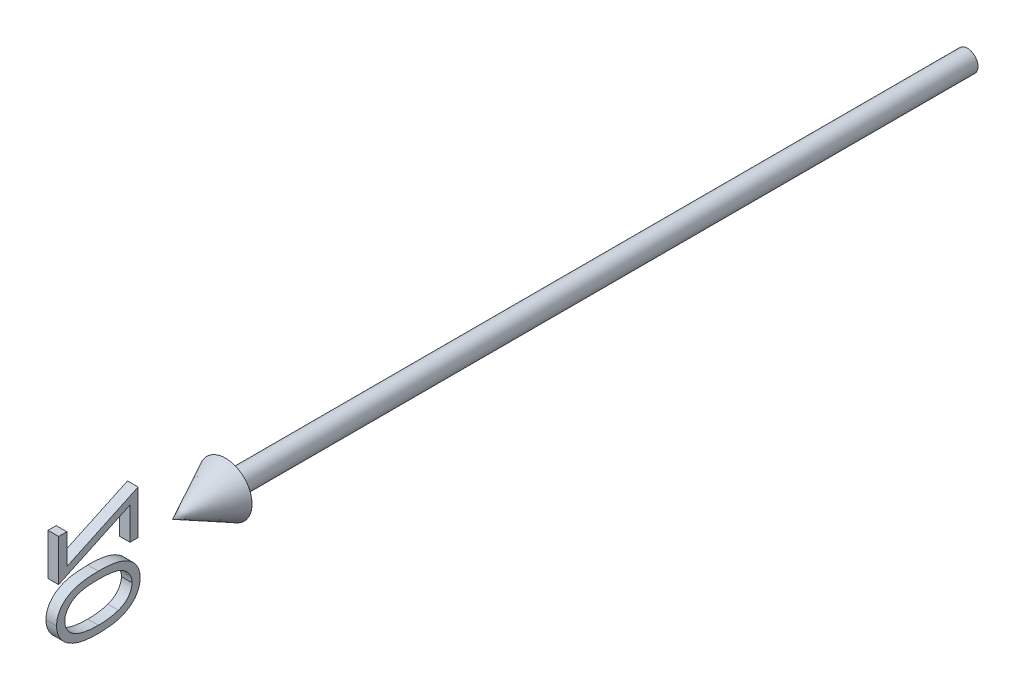
from build123d import *

# Parameters (mm, degrees)
BOSS_EXTRUDE1_DEPTH        = 1
BOSS_EXTRUDE1_DEPTH_BACK   = 1
BOSS_EXTRUDE1_2_DEPTH      = 1
BOSS_EXTRUDE1_2_DEPTH_BACK = 1


with BuildPart() as part:
    # Sketch2 → Revolve1 (revolve)
    with BuildSketch(Plane(origin=(0, 0, 0), x_dir=(1, 0, 0), z_dir=(0, 1, 0))):
        Polygon((0, -150), (5, -140), (2, -140), (2, 0), (0, 0), align=None)
    revolve(axis=Axis((0, 0, -41.949952025), (0, 0, 1)))


with BuildPart() as body_2:
    # Sketch3 → Boss-Extrude1 (new, two sides: drawn at the far end of the back side and taken through both)
    with BuildSketch(Plane(origin=(0, 0, 0), x_dir=(0, -1, 0), z_dir=(1, 0, 0)).offset(-BOSS_EXTRUDE1_DEPTH_BACK)):
        Polygon((-8.958586521, -170.961538462), (-8.958586521, -172.5), (-1.073971137, -172.5), (-7.366038444, -159.038461538), (-1.266278829, -159.038461538), (-1.266278829, -157.5), (-9.535509598, -157.5), (-3.243442291, -170.961538462), align=None)
    extrude(amount=BOSS_EXTRUDE1_DEPTH + BOSS_EXTRUDE1_DEPTH_BACK)


with BuildPart() as body_3:
    # Sketch3 → Boss-Extrude1 2 (new, two sides: drawn at the far end of the back side and taken through both)
    with BuildSketch(Plane(origin=(0, 0, 0), x_dir=(0, -1, 0), z_dir=(1, 0, 0)).offset(-BOSS_EXTRUDE1_2_DEPTH_BACK)):
        with BuildLine():
            add(Edge.make_bspline(
                [(0.464490402, -164.993990385), (0.465896194, -165.234407761), (0.468626965, -165.701421979), (0.499005913, -166.381927587), (0.549471662, -167.020328829), (0.618631845, -167.616656242), (0.702794571, -168.171063848), (0.815146812, -168.682069802), (0.942915443, -169.152040041), (1.090999113, -169.582504296), (1.258083581, -169.97927162), (1.439966057, -170.349645098), (1.643739441, -170.693182296), (1.858196956, -171.014944812), (2.090844214, -171.311694529), (2.340872181, -171.582097798), (2.606078592, -171.830344919), (2.88771833, -172.052353788), (3.183107018, -172.245804902), (3.483506669, -172.421163962), (3.7974853, -172.559877815), (4.117298457, -172.678494137), (4.445522801, -172.772454295), (4.782301317, -172.83781096), (5.127936212, -172.878699478), (5.361209824, -172.882624707), (5.47951444, -172.884615385)],
                knots=[0, 0, 0, 0, 1.64625301, 3.197870201, 4.6634513, 6.030635694, 7.308242971, 8.501545196, 9.611429483, 10.641742253, 11.616230371, 12.55791849, 13.464870342, 14.34944951, 15.20427819, 16.044004467, 16.869007726, 17.689551165, 18.496129964, 19.285613293, 20.0683943, 20.843080271, 21.620342827, 22.403213977, 23.190190624, 24, 24, 24, 24], degree=3))
            add(Edge.make_bspline(
                [(5.47951444, -172.884615385), (5.598867202, -172.882960028), (5.836337191, -172.879666451), (6.186159255, -172.83330737), (6.529888015, -172.773470363), (6.862308428, -172.677501658), (7.189705924, -172.562662656), (7.503938784, -172.411134418), (7.81610109, -172.246335691), (8.112011727, -172.045295108), (8.400511963, -171.823112179), (8.670950813, -171.570877754), (8.930241416, -171.295572446), (9.168590469, -170.991056145), (9.396213279, -170.661997985), (9.604469055, -170.305639513), (9.797689138, -169.922770469), (9.979505552, -169.515165777), (10.138499204, -169.071937683), (10.279857271, -168.595850718), (10.395724126, -168.082593685), (10.491543977, -167.535025751), (10.565918422, -166.950434272), (10.620046885, -166.330003698), (10.648649073, -165.673345879), (10.654034477, -165.224383527), (10.656798094, -164.993990385)],
                knots=[0, 0, 0, 0, 0.810910589, 1.61342667, 2.396193133, 3.181089899, 3.963115317, 4.752255436, 5.550715454, 6.36105385, 7.181178335, 8.024612154, 8.872680183, 9.750181803, 10.651284446, 11.591556747, 12.554036451, 13.566402641, 14.62422919, 15.753422176, 16.94128843, 18.199818041, 19.531985927, 20.947085226, 22.433341622, 24, 24, 24, 24], degree=3))
            add(Edge.make_bspline(
                [(10.656798094, -164.993990385), (10.653970235, -164.76460507), (10.648447932, -164.316656666), (10.620697831, -163.662910865), (10.564467416, -163.045865825), (10.495932708, -162.464627558), (10.397119068, -161.919955842), (10.287109959, -161.408925586), (10.146787166, -160.936338531), (9.991564806, -160.496909685), (9.812278245, -160.091031643), (9.620513341, -159.709742957), (9.409148778, -159.355406899), (9.185893633, -159.024263001), (8.943032158, -158.722358307), (8.687250529, -158.443973378), (8.414188003, -158.191300727), (8.124202643, -157.966494417), (7.825495117, -157.763939413), (7.513271955, -157.593264463), (7.19484201, -157.444470737), (6.866893202, -157.324857983), (6.531516762, -157.23030363), (6.187504946, -157.165936242), (5.836290408, -157.120565339), (5.598851553, -157.117117503), (5.47951444, -157.115384615)],
                knots=[0, 0, 0, 0, 1.561431216, 3.049195289, 4.452146966, 5.778046447, 7.031138842, 8.218704273, 9.334037798, 10.384210803, 11.388620812, 12.352076869, 13.287433199, 14.19507451, 15.06813243, 15.922055533, 16.766344942, 17.596869952, 18.417486629, 19.220035357, 20.016159057, 20.807716045, 21.59340902, 22.384936649, 23.188266813, 24, 24, 24, 24], degree=3))
            add(Edge.make_bspline(
                [(5.47951444, -157.115384615), (5.361213947, -157.117392936), (5.127948465, -157.121352952), (4.782254012, -157.161986641), (4.44596381, -157.2282465), (4.118405567, -157.318227047), (3.79890901, -157.432587032), (3.490603617, -157.578048524), (3.189418903, -157.746761869), (2.896724751, -157.938702433), (2.618116601, -158.158670648), (2.351933625, -158.401913689), (2.105142979, -158.674700197), (1.874100145, -158.972676287), (1.657863216, -159.295248786), (1.454952755, -159.641415946), (1.273624174, -160.015397496), (1.102751263, -160.414318699), (0.952125487, -160.847945893), (0.82060184, -161.319526651), (0.709715439, -161.832277591), (0.621392873, -162.386223255), (0.549036995, -162.980506102), (0.499055664, -163.616073151), (0.468642154, -164.291563074), (0.465899573, -164.755575249), (0.464490402, -164.993990385)],
                knots=[0, 0, 0, 0, 0.810976328, 1.599087026, 2.383086309, 3.159618043, 3.926613167, 4.707144544, 5.494386734, 6.292609454, 7.104690378, 7.92621526, 8.762510248, 9.62398222, 10.509836085, 11.424023232, 12.373226806, 13.358118208, 14.398657954, 15.5185989, 16.713620699, 17.994156382, 19.364120462, 20.818119981, 22.365111093, 24, 24, 24, 24], degree=3))
        make_face()
        with BuildLine():
            add(Edge.make_bspline(
                [(1.810644248, -165), (1.811167389, -164.799649235), (1.812182703, -164.41080774), (1.83793945, -163.846752781), (1.873790211, -163.31977478), (1.918892548, -162.830079427), (1.986439653, -162.379378135), (2.063076152, -161.965797374), (2.154996357, -161.59010201), (2.264292702, -161.249011116), (2.388785301, -160.937687279), (2.524493273, -160.647858324), (2.671494339, -160.375998911), (2.833161137, -160.123089909), (3.011809892, -159.890543875), (3.203453101, -159.677256374), (3.40920511, -159.484095851), (3.69396548, -159.254853448), (4.068073456, -159.015172264), (4.541843799, -158.809023667), (5.028878765, -158.678635048), (5.35954219, -158.662099539), (5.524586556, -158.653846154)],
                knots=[0, 0, 0, 0, 1.459193451, 2.832007961, 4.111736495, 5.306635028, 6.412683014, 7.430020708, 8.369596877, 9.227877302, 10.036669781, 10.810175692, 11.557788084, 12.286326232, 12.994037279, 13.69140682, 14.37267704, 15.047194847, 16.352618509, 17.594157723, 18.799169539, 20, 20, 20, 20], degree=3))
            add(Edge.make_bspline(
                [(5.524586556, -158.653846154), (5.690578634, -158.661083242), (6.021973981, -158.675531747), (6.508677441, -158.801632605), (6.977262383, -159.006632555), (7.347064651, -159.240840139), (7.627622934, -159.46531168), (7.828712483, -159.656474594), (8.013259468, -159.870583043), (8.188298224, -160.101576726), (8.34883676, -160.35388829), (8.494821738, -160.626299066), (8.628036056, -160.919567044), (8.703931971, -161.124294488), (8.742735594, -161.228966346)],
                knots=[0, 0, 0, 0, 1.353621445, 2.702441307, 4.075953605, 5.516772412, 6.261413105, 7.007624062, 7.778524365, 8.566925914, 9.372323995, 10.217594641, 11.088702136, 12, 12, 12, 12], degree=3))
            add(Edge.make_bspline(
                [(8.742735594, -161.228966346), (8.787957456, -161.362808087), (8.87977723, -161.634564219), (8.998113405, -162.056122728), (9.091307973, -162.498420288), (9.175150969, -162.958813645), (9.232378352, -163.440698078), (9.278440408, -163.942582581), (9.305571924, -164.464845562), (9.308935143, -164.819681238), (9.310644248, -165)],
                knots=[0, 0, 0, 0, 0.884706709, 1.796334032, 2.740027952, 3.714592787, 4.726048262, 5.777819803, 6.87074269, 8, 8, 8, 8], degree=3))
            add(Edge.make_bspline(
                [(9.310644248, -165), (9.308759288, -165.180314886), (9.305071447, -165.533092983), (9.280841997, -166.049207658), (9.241907287, -166.540261981), (9.189210007, -167.006701417), (9.116867799, -167.447695775), (9.029991961, -167.863876052), (8.928140168, -168.255130252), (8.81131258, -168.622466686), (8.679651387, -168.964567475), (8.534198771, -169.282169041), (8.379003517, -169.576984364), (8.210328001, -169.848065186), (8.030558699, -170.096993279), (7.833240727, -170.318038475), (7.630907566, -170.521954006), (7.343146993, -170.750558338), (6.969481185, -170.985487037), (6.501307362, -171.195801559), (6.016767644, -171.320271369), (5.688528625, -171.337532574), (5.524586556, -171.346153846)],
                knots=[0, 0, 0, 0, 1.313528337, 2.569860077, 3.762944266, 4.901481389, 5.988248151, 7.017139294, 7.997571128, 8.932104357, 9.823695246, 10.66607014, 11.475539426, 12.248954257, 12.990316782, 13.708962568, 14.405488541, 15.08007697, 16.381737273, 17.610043218, 18.806313575, 20, 20, 20, 20], degree=3))
            add(Edge.make_bspline(
                [(5.524586556, -171.346153846), (5.35865184, -171.337522373), (5.026480116, -171.320243702), (4.536871559, -171.196240709), (4.065895038, -170.986982861), (3.693016666, -170.750267831), (3.409307178, -170.522841806), (3.207414438, -170.328738505), (3.016880382, -170.117445687), (2.839087451, -169.885954024), (2.678407031, -169.633527275), (2.529619301, -169.363638683), (2.394994046, -169.07424026), (2.270031538, -168.763088489), (2.161894888, -168.421437119), (2.064667433, -168.04581668), (1.989622468, -167.629546224), (1.922989134, -167.17672844), (1.872621908, -166.686450873), (1.83818931, -166.158225389), (1.812104472, -165.592204172), (1.811140738, -165.201355072), (1.810644248, -165)],
                knots=[0, 0, 0, 0, 1.207779899, 2.417760083, 3.652287919, 4.947299644, 5.621638849, 6.297435916, 6.984320042, 7.691843698, 8.42018894, 9.161205785, 9.934506883, 10.743085206, 11.601138371, 12.542248028, 13.566483018, 14.679455109, 15.87477181, 17.154161492, 18.533899613, 20, 20, 20, 20], degree=3))
        make_face(mode=Mode.SUBTRACT)
    extrude(amount=BOSS_EXTRUDE1_2_DEPTH + BOSS_EXTRUDE1_2_DEPTH_BACK)


solid = Compound([part.part, body_2.part, body_3.part])
